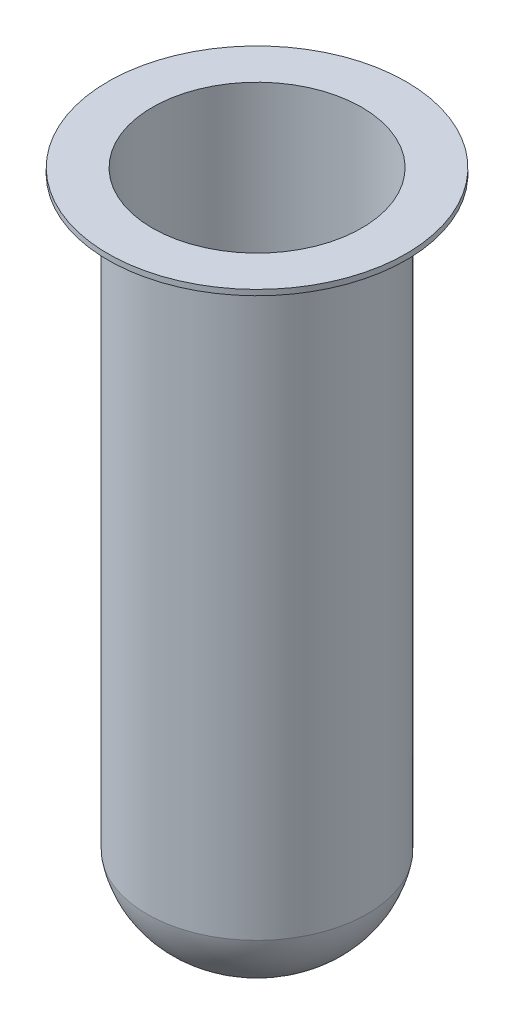
from build123d import *


with BuildPart() as part:
    # Sketch2 → Revolve2 (revolve)
    with BuildSketch(Plane.XY):
        with BuildLine():
            Line((20, 120), (20, 13.692287852))
            ThreePointArc((20, 13.692287852), (12.835765664, 2.704008302), (0, 0))
            Line((0, 0), (0, 0.929650957))
            Line((0, 0.929650957), (0.184018204, 0.982922835))
            ThreePointArc((0.184018204, 0.982922835), (12.233100998, 3.503391888), (19, 13.786496394))
            Line((19, 13.786496394), (19, 121))
            Line((19, 121), (27.059808742, 121))
            Line((27.059808742, 121), (27.059808742, 120))
            Line((27.059808742, 120), (20, 120))
        make_face()
    revolve(axis=Axis((0, 0, 0), (0, 1, 0)))


solid = part.part
